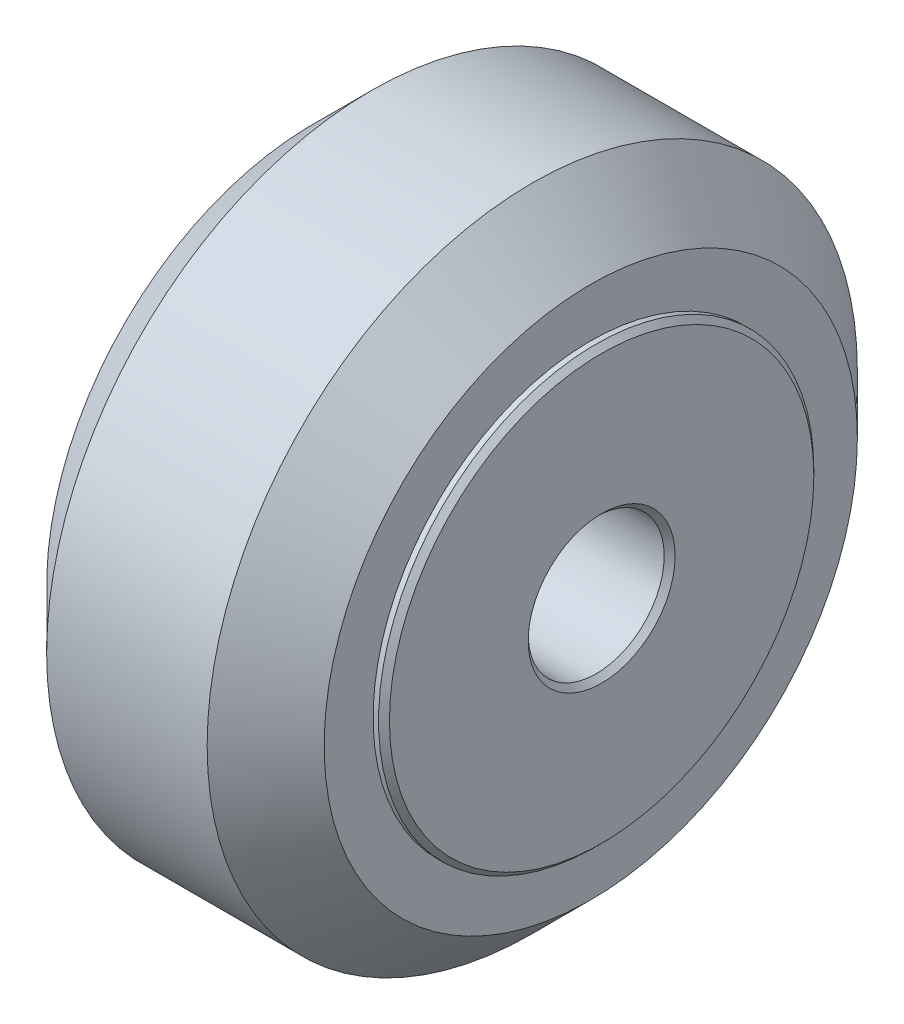
from build123d import *

# Parameters (mm, degrees)
SKETCH2_R           = 8
SKETCH2_R_2         = 2.5
BEARING_DEPTH       = 5
SKETCH3_R           = 5
SKETCH3_R_2         = 2.5
BOSS_EXTRUDE1_DEPTH = 0.5
SKETCH4_R           = 8
SKETCH4_R_2         = 2.5
BOSS_EXTRUDE2_DEPTH = 5
CHAMFER1_SIZE       = 0.2
CHAMFER2_SIZE       = 0.2


with BuildPart() as part:
    # Sketch1 → Revolve1 (revolve)
    with BuildSketch(Plane.XY):
        Polygon((-0.5, 8), (-0.5, 7), (0.5, 7), (0.5, 8), (5.1, 8), (5.1, 9.8), (2.95, 11.95), (-2.95, 11.95), (-5.1, 9.8), (-5.1, 8), align=None)
    revolve(axis=Axis((-5.1, 0, 0), (1, 0, 0)))


with BuildPart() as body_2:
    # Sketch2 → bearing (new body)
    with BuildSketch(Plane(origin=(0.5, 0, 0), x_dir=(0, 0, -1), z_dir=(1, 0, 0))):
        Circle(SKETCH2_R)
        Circle(SKETCH2_R_2, mode=Mode.SUBTRACT)
    extrude(amount=BEARING_DEPTH)

    # Chamfer1
    chamfer1_edges = [body_2.edges().sort_by_distance(p)[0] for p in [
        (5.5, 0, 8),
        (5.5, 0, 2.5),
    ]]
    chamfer(chamfer1_edges, length=CHAMFER1_SIZE)


with BuildPart() as body_3:
    # Sketch3 → Boss-Extrude1 (new body, symmetric)
    with BuildSketch(Plane(origin=(0, 0, 0), x_dir=(0, 0, -1), z_dir=(1, 0, 0))):
        Circle(SKETCH3_R)
        Circle(SKETCH3_R_2, mode=Mode.SUBTRACT)
    extrude(amount=BOSS_EXTRUDE1_DEPTH, both=True)


with BuildPart() as body_4:
    # Sketch4 → Boss-Extrude2 (new body)
    with BuildSketch(Plane.ZY.offset(0.5)):
        Circle(SKETCH4_R)
        Circle(SKETCH4_R_2, mode=Mode.SUBTRACT)
    extrude(amount=BOSS_EXTRUDE2_DEPTH)

    # Chamfer2
    chamfer2_edges = [body_4.edges().sort_by_distance(p)[0] for p in [
        (-5.5, 0, -8),
        (-5.5, 0, -2.5),
    ]]
    chamfer(chamfer2_edges, length=CHAMFER2_SIZE)


solid = Compound([part.part, body_2.part, body_3.part, body_4.part])
